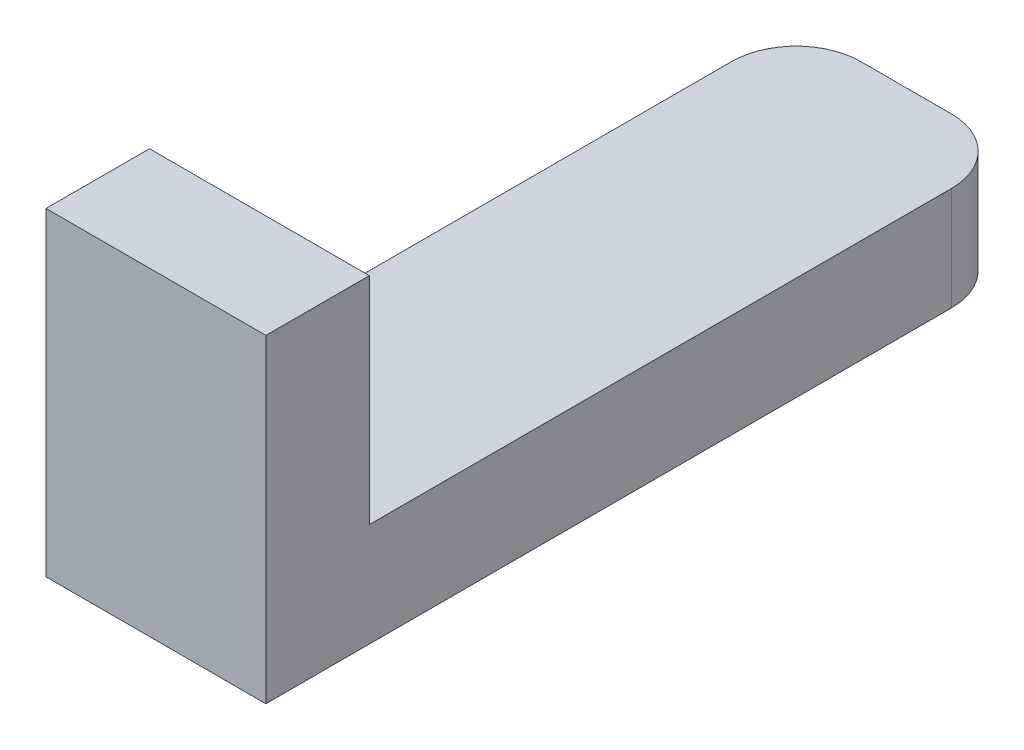
from build123d import *

# Parameters (mm, degrees)
BOSS_EXTRUDE1_DEPTH = 6.477
FILLET1_R           = 1.905


with BuildPart() as part:
    # Sketch1 → Boss-Extrude1 (new body)
    with BuildSketch(Plane(origin=(0, 0, 0), x_dir=(0, 0, -1), z_dir=(1, 0, 0))):
        Polygon((-22.098, 0), (0, 0), (0, 3.048), (-19.05, 3.048), (-19.05, 9.398), (-22.098, 9.398), align=None)
    extrude(amount=BOSS_EXTRUDE1_DEPTH)

    # Fillet1
    fillet1_edges = [part.edges().sort_by_distance(p)[0] for p in [
        (6.477, 1.524, 0),
        (0, 1.524, 0),
    ]]
    fillet(fillet1_edges, radius=FILLET1_R)


solid = part.part
